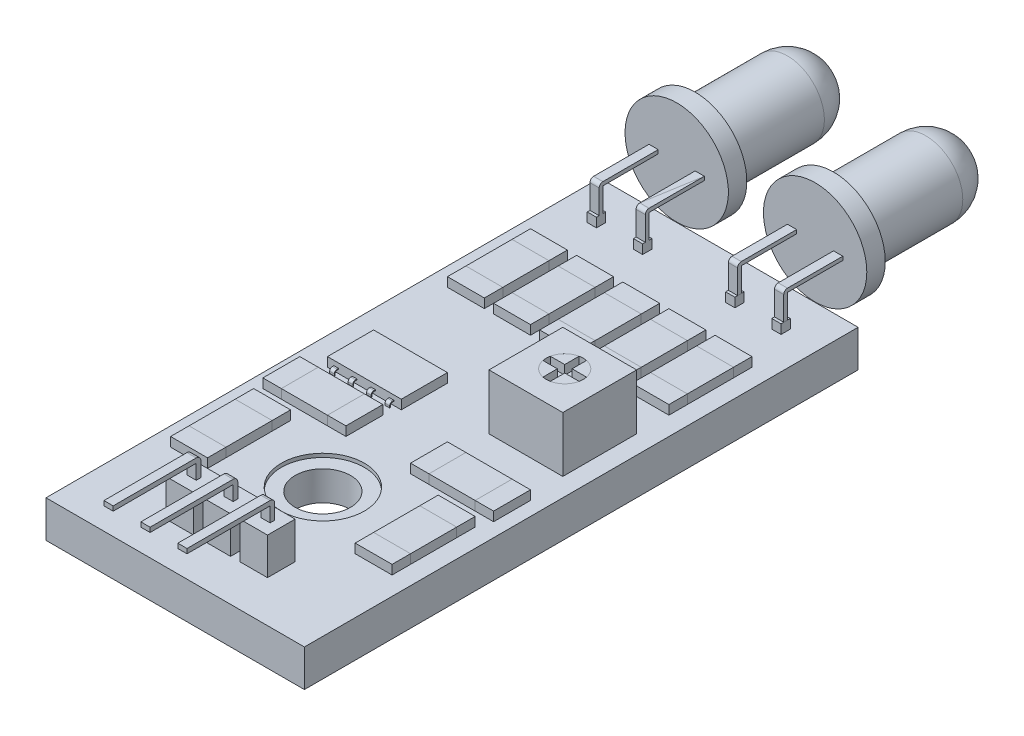
from build123d import *

# Parameters (mm, degrees)
CROQUIS1_W                 = 14
CROQUIS1_H                 = 30
SALIENTE_EXTRUIR1_DEPTH    = 1
CROQUIS2_R                 = 1.5
CORTAR_EXTRUIR1_DEPTH      = 2
CROQUIS3_R                 = 2.25
CORTAR_EXTRUIR2_DEPTH      = 0.2
CROQUIS4_W                 = 1.5
CROQUIS4_H                 = 1.5
SALIENTE_EXTRUIR2_DEPTH    = 2
SALIENTE_EXTRUIR3_START    = -0.75
SALIENTE_EXTRUIR3_DEPTH    = 0.25
MATRIZL1_COUNT             = 3
MATRIZL1_PITCH             = 2
CROQUIS6_W                 = 2
CROQUIS6_H                 = 2.5
SALIENTE_EXTRUIR4_DEPTH    = 0.5
CROQUIS6_3_W               = 2
CROQUIS6_3_H               = 1
SALIENTE_EXTRUIR5_DEPTH    = 0.5
SALIENTE_EXTRUIR5_2_DEPTH  = 0.5
CROQUIS8_W                 = 2.5
CROQUIS8_H                 = 2
SALIENTE_EXTRUIR6_DEPTH    = 0.5
CROQUIS8_3_W               = 1
CROQUIS8_3_H               = 2
SALIENTE_EXTRUIR7_DEPTH    = 0.5
SALIENTE_EXTRUIR7_2_DEPTH  = 0.5
CROQUIS9_W                 = 4
CROQUIS9_H                 = 2.5
SALIENTE_EXTRUIR8_DEPTH    = 0.5
SALIENTE_EXTRUIR9_START    = -0.6
SALIENTE_EXTRUIR9_DEPTH    = 0.25
SALIENTE_EXTRUIR9_2_DEPTH  = 0.25
MATRIZL4_COUNT             = 4
MATRIZL4_PITCH             = 1
CROQUIS11_W                = 4
CROQUIS11_H                = 4
SALIENTE_EXTRUIR10_DEPTH   = 3
CROQUIS12_R                = 1
CORTAR_EXTRUIR3_DEPTH      = 1
CROQUIS13_R                = 1
SALIENTE_EXTRUIR11_DEPTH   = 0.5
SALIENTE_EXTRUIR12_DEPTH   = 0.5
SALIENTE_EXTRUIR12_2_DEPTH = 0.5
SALIENTE_EXTRUIR12_3_DEPTH = 0.5
SALIENTE_EXTRUIR12_4_DEPTH = 0.5
CROQUIS15_W                = 2
CROQUIS15_H                = 2.5
SALIENTE_EXTRUIR13_DEPTH   = 0.5
CROQUIS15_4_W              = 2
CROQUIS15_4_H              = 1
SALIENTE_EXTRUIR14_DEPTH   = 0.5
SALIENTE_EXTRUIR14_2_DEPTH = 0.5
MATRIZL5_COUNT             = 5
MATRIZL5_PITCH             = 2.5
CROQUIS17_W                = 0.5
CROQUIS17_H                = 0.5
SALIENTE_EXTRUIR15_DEPTH   = 0.5
SALIENTE_EXTRUIR15_2_DEPTH = 0.5
SALIENTE_EXTRUIR15_3_DEPTH = 0.5
SALIENTE_EXTRUIR15_4_DEPTH = 0.5
SALIENTE_EXTRUIR16_START   = -0.25
SALIENTE_EXTRUIR16_DEPTH   = 0.25
MATRIZL6_COUNT             = 2
MATRIZL6_PITCH             = 2.5
SIMETR_A16_START           = -0.25
SIMETR_A16_COPY_1_DEPTH    = 0.25


with BuildPart() as part:
    # Croquis1 → Saliente-Extruir1 (new, symmetric)
    with BuildSketch(Plane(origin=(0, 0, 0), x_dir=(1, 0, 0), z_dir=(0, 1, 0))):
        Rectangle(CROQUIS1_W, CROQUIS1_H)
    extrude(amount=SALIENTE_EXTRUIR1_DEPTH, both=True)

    # Croquis2 → Cortar-Extruir1 (cut)
    with BuildSketch(Plane(origin=(0, 1, 0), x_dir=(1, 0, 0), z_dir=(0, 1, 0))):
        with Locations((0, -7)):
            Circle(CROQUIS2_R)
    extrude(amount=-CORTAR_EXTRUIR1_DEPTH, mode=Mode.SUBTRACT)

    # Croquis3 → Cortar-Extruir2 (cut)
    with BuildSketch(Plane(origin=(0, 1, 0), x_dir=(1, 0, 0), z_dir=(0, 1, 0))):
        with Locations((0, -7)):
            Circle(CROQUIS3_R)
    cortar_extruir2 = extrude(amount=-CORTAR_EXTRUIR2_DEPTH, mode=Mode.SUBTRACT)

    # Simetría1: Cortar-Extruir2 across plane
    add(cortar_extruir2.mirror(Plane.ZX), mode=Mode.SUBTRACT)

    # Croquis4 → Saliente-Extruir2 (add)
    with BuildSketch(Plane(origin=(0, 1, 0), x_dir=(1, 0, 0), z_dir=(0, 1, 0))):
        with Locations((-2, -12)):
            Rectangle(CROQUIS4_W, CROQUIS4_H)
        with Locations((0, -12)):
            Rectangle(CROQUIS4_W, CROQUIS4_H)
        with Locations((2, -12)):
            Rectangle(CROQUIS4_W, CROQUIS4_H)
    extrude(amount=SALIENTE_EXTRUIR2_DEPTH)


with BuildPart() as body_2:
    # Croquis5 → Saliente-Extruir3 (new, symmetric)
    with BuildSketch(Plane(origin=(2.75, 0, 0), x_dir=(0, 0, -1), z_dir=(1, 0, 0)).offset(SALIENTE_EXTRUIR3_START)):
        with BuildLine():
            Line((-11.860160095, 3), (-11.860160095, 3.8))
            ThreePointArc((-11.860160095, 3.8), (-11.9333834, 3.976776695), (-12.110160095, 4.05))
            Line((-12.110160095, 4.05), (-16.610160095, 4.05))
            Line((-16.610160095, 4.05), (-16.610160095, 3.8))
            Line((-16.610160095, 3.8), (-12.110160095, 3.8))
            Line((-12.110160095, 3.8), (-12.110160095, 3))
            Line((-12.110160095, 3), (-11.860160095, 3))
        make_face()
    saliente_extruir3 = extrude(amount=SALIENTE_EXTRUIR3_DEPTH, both=True)


with BuildPart() as matrizl1_1:
    # MatrizL1: Saliente-Extruir3 ×3
    with Locations(*[(-i * MATRIZL1_PITCH, 0, 0) for i in range(1, MATRIZL1_COUNT)]):
        add(saliente_extruir3)


with BuildPart() as body_5:
    # Croquis6 → Saliente-Extruir4 (new body)
    with BuildSketch(Plane(origin=(0, 1, 0), x_dir=(1, 0, 0), z_dir=(0, 1, 0))):
        with Locations((5, -6.9999)):
            Rectangle(CROQUIS6_W, CROQUIS6_H)
    extrude(amount=SALIENTE_EXTRUIR4_DEPTH)


with BuildPart() as body_6:
    # Croquis6_3 → Saliente-Extruir5 (new body)
    with BuildSketch(Plane(origin=(0, 1, 0), x_dir=(1, 0, 0), z_dir=(0, 1, 0))):
        with Locations((5, -5.2499)):
            Rectangle(CROQUIS6_3_W, CROQUIS6_3_H)
    extrude(amount=SALIENTE_EXTRUIR5_DEPTH)


with BuildPart() as body_7:
    # Croquis6_3 → Saliente-Extruir5 2 (new body)
    with BuildSketch(Plane(origin=(0, 1, 0), x_dir=(1, 0, 0), z_dir=(0, 1, 0))):
        with Locations((5, -8.7499)):
            Rectangle(CROQUIS6_3_W, CROQUIS6_3_H)
    extrude(amount=SALIENTE_EXTRUIR5_2_DEPTH)


with BuildPart() as body_8:
    # Simetría14: mirrored copy
    add(body_6.part.mirror(Plane(origin=(0, 0, 0), x_dir=(0, 0, 1), z_dir=(1, 0, 0))))


with BuildPart() as body_9:
    # Simetr_a14 2: mirrored copy
    add(body_5.part.mirror(Plane(origin=(0, 0, 0), x_dir=(0, 0, 1), z_dir=(1, 0, 0))))


with BuildPart() as body_10:
    # Simetr_a14 3: mirrored copy
    add(body_7.part.mirror(Plane(origin=(0, 0, 0), x_dir=(0, 0, 1), z_dir=(1, 0, 0))))


with BuildPart() as body_11:
    # Croquis8 → Saliente-Extruir6 (new body)
    with BuildSketch(Plane(origin=(0, 1, 0), x_dir=(1, 0, 0), z_dir=(0, 1, 0))):
        with Locations((4, -3)):
            Rectangle(CROQUIS8_W, CROQUIS8_H)
    extrude(amount=SALIENTE_EXTRUIR6_DEPTH)


with BuildPart() as body_12:
    # Croquis8_3 → Saliente-Extruir7 (new body)
    with BuildSketch(Plane(origin=(0, 1, 0), x_dir=(1, 0, 0), z_dir=(0, 1, 0))):
        with Locations((2.25, -3)):
            Rectangle(CROQUIS8_3_W, CROQUIS8_3_H)
    extrude(amount=SALIENTE_EXTRUIR7_DEPTH)


with BuildPart() as body_13:
    # Croquis8_3 → Saliente-Extruir7 2 (new body)
    with BuildSketch(Plane(origin=(0, 1, 0), x_dir=(1, 0, 0), z_dir=(0, 1, 0))):
        with Locations((5.75, -3)):
            Rectangle(CROQUIS8_3_W, CROQUIS8_3_H)
    extrude(amount=SALIENTE_EXTRUIR7_2_DEPTH)


with BuildPart() as body_14:
    # Simetría15: mirrored copy
    add(body_11.part.mirror(Plane(origin=(0, 0, 0), x_dir=(0, 0, 1), z_dir=(1, 0, 0))))


with BuildPart() as body_15:
    # Simetr_a15 2: mirrored copy
    add(body_13.part.mirror(Plane(origin=(0, 0, 0), x_dir=(0, 0, 1), z_dir=(1, 0, 0))))


with BuildPart() as body_16:
    # Simetr_a15 3: mirrored copy
    add(body_12.part.mirror(Plane(origin=(0, 0, 0), x_dir=(0, 0, 1), z_dir=(1, 0, 0))))


with BuildPart() as body_17:
    # Croquis9 → Saliente-Extruir8 (new body)
    with BuildSketch(Plane(origin=(0, 1, 0), x_dir=(1, 0, 0), z_dir=(0, 1, 0))):
        with Locations((-3.5, 0)):
            Rectangle(CROQUIS9_W, CROQUIS9_H)
    extrude(amount=SALIENTE_EXTRUIR8_DEPTH)


with BuildPart() as body_18:
    # Croquis10 → Saliente-Extruir9 (new body)
    with BuildSketch(Plane.ZY.offset(5.5).offset(SALIENTE_EXTRUIR9_START)):
        with BuildLine():
            Line((1.25, 1.25), (1.33, 1.25))
            ThreePointArc((1.33, 1.25), (1.436066017, 1.206066017), (1.48, 1.1))
            Line((1.48, 1.1), (1.48, 1))
            Line((1.48, 1), (1.43, 1))
            Line((1.43, 1), (1.43, 1.1))
            ThreePointArc((1.43, 1.1), (1.400710678, 1.170710678), (1.33, 1.2))
            Line((1.33, 1.2), (1.25, 1.2))
            Line((1.25, 1.2), (1.25, 1.25))
        make_face()
    saliente_extruir9 = extrude(amount=SALIENTE_EXTRUIR9_DEPTH)


with BuildPart() as body_19:
    # Croquis10 → Saliente-Extruir9 2 (new body)
    with BuildSketch(Plane.ZY.offset(5.5).offset(SALIENTE_EXTRUIR9_START)):
        with BuildLine():
            Line((-1.48, 1), (-1.43, 1))
            Line((-1.43, 1), (-1.43, 1.1))
            ThreePointArc((-1.43, 1.1), (-1.400710678, 1.170710678), (-1.33, 1.2))
            Line((-1.33, 1.2), (-1.25, 1.2))
            Line((-1.25, 1.2), (-1.25, 1.25))
            Line((-1.25, 1.25), (-1.33, 1.25))
            ThreePointArc((-1.33, 1.25), (-1.436066017, 1.206066017), (-1.48, 1.1))
            Line((-1.48, 1.1), (-1.48, 1))
        make_face()
    saliente_extruir9_2 = extrude(amount=SALIENTE_EXTRUIR9_2_DEPTH)


with BuildPart() as matrizl4_1:
    # MatrizL4: Saliente-Extruir9, Saliente-Extruir9 2 ×4
    with Locations(*[(i * MATRIZL4_PITCH, 0, 0) for i in range(1, MATRIZL4_COUNT)]):
        add(saliente_extruir9)
        add(saliente_extruir9_2)


with BuildPart() as body_26:
    # Croquis11 → Saliente-Extruir10 (new body)
    with BuildSketch(Plane(origin=(0, 1, 0), x_dir=(1, 0, 0), z_dir=(0, 1, 0))):
        with Locations((4, 2)):
            Rectangle(CROQUIS11_W, CROQUIS11_H)
    extrude(amount=SALIENTE_EXTRUIR10_DEPTH)

    # Croquis12 → Cortar-Extruir3 (cut)
    with BuildSketch(Plane(origin=(0, 4, 0), x_dir=(1, 0, 0), z_dir=(0, 1, 0))):
        with Locations((4, 2.104018111)):
            Circle(CROQUIS12_R)
    extrude(amount=-CORTAR_EXTRUIR3_DEPTH, mode=Mode.SUBTRACT)


with BuildPart() as body_27:
    # Croquis13 → Saliente-Extruir11 (new body)
    with BuildSketch(Plane(origin=(0, 3, 0), x_dir=(1, 0, 0), z_dir=(0, 1, 0))):
        with Locations((4, 2.104018111)):
            Circle(CROQUIS13_R)
    extrude(amount=SALIENTE_EXTRUIR11_DEPTH)


with BuildPart() as body_28:
    # Croquis14 → Saliente-Extruir12 (new body)
    with BuildSketch(Plane(origin=(0, 3.5, 0), x_dir=(1, 0, 0), z_dir=(0, 1, 0))):
        with BuildLine():
            Line((3.8, 2.304018111), (3.8, 3.083814008))
            ThreePointArc((3.8, 3.083814008), (3.292893219, 2.811124892), (3.020204103, 2.304018111))
            Line((3.020204103, 2.304018111), (3.8, 2.304018111))
        make_face()
    extrude(amount=SALIENTE_EXTRUIR12_DEPTH)


with BuildPart() as body_29:
    # Croquis14 → Saliente-Extruir12 2 (new body)
    with BuildSketch(Plane(origin=(0, 3.5, 0), x_dir=(1, 0, 0), z_dir=(0, 1, 0))):
        with BuildLine():
            ThreePointArc((4.979795897, 2.304018111), (4.707106781, 2.811124892), (4.2, 3.083814008))
            Line((4.2, 3.083814008), (4.2, 2.304018111))
            Line((4.2, 2.304018111), (4.979795897, 2.304018111))
        make_face()
    extrude(amount=SALIENTE_EXTRUIR12_2_DEPTH)


with BuildPart() as body_30:
    # Croquis14 → Saliente-Extruir12 3 (new body)
    with BuildSketch(Plane(origin=(0, 3.5, 0), x_dir=(1, 0, 0), z_dir=(0, 1, 0))):
        with BuildLine():
            Line((3.8, 1.124222214), (3.8, 1.904018111))
            Line((3.8, 1.904018111), (3.020204103, 1.904018111))
            ThreePointArc((3.020204103, 1.904018111), (3.292893219, 1.39691133), (3.8, 1.124222214))
        make_face()
    extrude(amount=SALIENTE_EXTRUIR12_3_DEPTH)


with BuildPart() as body_31:
    # Croquis14 → Saliente-Extruir12 4 (new body)
    with BuildSketch(Plane(origin=(0, 3.5, 0), x_dir=(1, 0, 0), z_dir=(0, 1, 0))):
        with BuildLine():
            Line((4.979795897, 1.904018111), (4.2, 1.904018111))
            Line((4.2, 1.904018111), (4.2, 1.124222214))
            ThreePointArc((4.2, 1.124222214), (4.707106781, 1.39691133), (4.979795897, 1.904018111))
        make_face()
    extrude(amount=SALIENTE_EXTRUIR12_4_DEPTH)


with BuildPart() as body_32:
    # Croquis15 → Saliente-Extruir13 (new body)
    with BuildSketch(Plane(origin=(0, 1, 0), x_dir=(1, 0, 0), z_dir=(0, 1, 0))):
        with Locations((5, 8)):
            Rectangle(CROQUIS15_W, CROQUIS15_H)
    extrude(amount=SALIENTE_EXTRUIR13_DEPTH)


with BuildPart() as body_33:
    # Croquis15_4 → Saliente-Extruir14 (new body)
    with BuildSketch(Plane(origin=(0, 1, 0), x_dir=(1, 0, 0), z_dir=(0, 1, 0))):
        with Locations((5, 6.25)):
            Rectangle(CROQUIS15_4_W, CROQUIS15_4_H)
    extrude(amount=SALIENTE_EXTRUIR14_DEPTH)


with BuildPart() as body_34:
    # Croquis15_4 → Saliente-Extruir14 2 (new body)
    with BuildSketch(Plane(origin=(0, 1, 0), x_dir=(1, 0, 0), z_dir=(0, 1, 0))):
        with Locations((5, 9.75)):
            Rectangle(CROQUIS15_4_W, CROQUIS15_4_H)
    extrude(amount=SALIENTE_EXTRUIR14_2_DEPTH)


with BuildPart() as matrizl5_1:
    # MatrizL5: pattern copy
    add(body_33.part.moved(Location(Vector(-1, 0, 0) * (1 * MATRIZL5_PITCH))))


with BuildPart() as matrizl5_2:
    # MatrizL5: pattern copy
    add(body_33.part.moved(Location(Vector(-1, 0, 0) * (2 * MATRIZL5_PITCH))))


with BuildPart() as matrizl5_3:
    # MatrizL5: pattern copy
    add(body_33.part.moved(Location(Vector(-1, 0, 0) * (3 * MATRIZL5_PITCH))))


with BuildPart() as matrizl5_4:
    # MatrizL5: pattern copy
    add(body_33.part.moved(Location(Vector(-1, 0, 0) * (4 * MATRIZL5_PITCH))))


with BuildPart() as matrizl5_5:
    # MatrizL5: pattern copy
    add(body_32.part.moved(Location(Vector(-1, 0, 0) * (1 * MATRIZL5_PITCH))))


with BuildPart() as matrizl5_6:
    # MatrizL5: pattern copy
    add(body_32.part.moved(Location(Vector(-1, 0, 0) * (2 * MATRIZL5_PITCH))))


with BuildPart() as matrizl5_7:
    # MatrizL5: pattern copy
    add(body_32.part.moved(Location(Vector(-1, 0, 0) * (3 * MATRIZL5_PITCH))))


with BuildPart() as matrizl5_8:
    # MatrizL5: pattern copy
    add(body_32.part.moved(Location(Vector(-1, 0, 0) * (4 * MATRIZL5_PITCH))))


with BuildPart() as matrizl5_9:
    # MatrizL5: pattern copy
    add(body_34.part.moved(Location(Vector(-1, 0, 0) * (1 * MATRIZL5_PITCH))))


with BuildPart() as matrizl5_10:
    # MatrizL5: pattern copy
    add(body_34.part.moved(Location(Vector(-1, 0, 0) * (2 * MATRIZL5_PITCH))))


with BuildPart() as matrizl5_11:
    # MatrizL5: pattern copy
    add(body_34.part.moved(Location(Vector(-1, 0, 0) * (3 * MATRIZL5_PITCH))))


with BuildPart() as matrizl5_12:
    # MatrizL5: pattern copy
    add(body_34.part.moved(Location(Vector(-1, 0, 0) * (4 * MATRIZL5_PITCH))))


with BuildPart() as body_47:
    # Croquis17 → Saliente-Extruir15 (new body)
    with BuildSketch(Plane(origin=(0, 1, 0), x_dir=(1, 0, 0), z_dir=(0, 1, 0))):
        with Locations((-5, 12.824726242)):
            Rectangle(CROQUIS17_W, CROQUIS17_H)
    extrude(amount=SALIENTE_EXTRUIR15_DEPTH)


with BuildPart() as body_48:
    # Croquis17 → Saliente-Extruir15 2 (new body)
    with BuildSketch(Plane(origin=(0, 1, 0), x_dir=(1, 0, 0), z_dir=(0, 1, 0))):
        with Locations((-2.5, 12.824726242)):
            Rectangle(CROQUIS17_W, CROQUIS17_H)
    extrude(amount=SALIENTE_EXTRUIR15_2_DEPTH)


with BuildPart() as body_49:
    # Croquis17 → Saliente-Extruir15 3 (new body)
    with BuildSketch(Plane(origin=(0, 1, 0), x_dir=(1, 0, 0), z_dir=(0, 1, 0))):
        with Locations((2.5, 12.824726242)):
            Rectangle(CROQUIS17_W, CROQUIS17_H)
    extrude(amount=SALIENTE_EXTRUIR15_3_DEPTH)


with BuildPart() as body_50:
    # Croquis17 → Saliente-Extruir15 4 (new body)
    with BuildSketch(Plane(origin=(0, 1, 0), x_dir=(1, 0, 0), z_dir=(0, 1, 0))):
        with Locations((5, 12.824726242)):
            Rectangle(CROQUIS17_W, CROQUIS17_H)
    extrude(amount=SALIENTE_EXTRUIR15_4_DEPTH)


with BuildPart() as body_51:
    # Croquis18 → Saliente-Extruir16 (new, symmetric)
    with BuildSketch(Plane(origin=(5.25, 0, 0), x_dir=(0, 0, -1), z_dir=(1, 0, 0)).offset(SALIENTE_EXTRUIR16_START)):
        with BuildLine():
            Line((12.721362623, 1.5), (12.721362623, 2.8))
            ThreePointArc((12.721362623, 2.8), (12.779941267, 2.941421356), (12.921362623, 3))
            Line((12.921362623, 3), (15.921362623, 3))
            Line((15.921362623, 3), (15.921362623, 2.8))
            Line((15.921362623, 2.8), (12.921362623, 2.8))
            Line((12.921362623, 2.8), (12.921362623, 1.5))
            Line((12.921362623, 1.5), (12.721362623, 1.5))
        make_face()
    saliente_extruir16 = extrude(amount=SALIENTE_EXTRUIR16_DEPTH, both=True)



with BuildPart() as matrizl6_1:
    # MatrizL6: Saliente-Extruir16 ×2
    with Locations(*[(-i * MATRIZL6_PITCH, 0, 0) for i in range(1, MATRIZL6_COUNT)]):
        add(saliente_extruir16)


with BuildPart() as body_47_1:
    add(body_47.part)

    # Simetría16: Saliente-Extruir16 across plane
    add(saliente_extruir16.mirror(Plane(origin=(0, 0, 0), x_dir=(0, 0, 1), z_dir=(1, 0, 0))))

    add(body_48.part)  # Simetría16 copy 1 merges body 48
    # Simetría16 copy 1 sketch → Simetría16 copy 1 (add, symmetric)
    with BuildSketch(Plane(origin=(-2.75, 0, 0), x_dir=(0, 0, -1), z_dir=(-1, 0, 0)).offset(SIMETR_A16_START)):
        with BuildLine():
            Line((12.721362623, -1.5), (12.721362623, -2.8))
            ThreePointArc((12.721362623, -2.8), (12.779941267, -2.941421356), (12.921362623, -3))
            Line((12.921362623, -3), (15.921362623, -3))
            Line((15.921362623, -3), (15.921362623, -2.8))
            Line((15.921362623, -2.8), (12.921362623, -2.8))
            Line((12.921362623, -2.8), (12.921362623, -1.5))
            Line((12.921362623, -1.5), (12.721362623, -1.5))
        make_face()
    extrude(amount=SIMETR_A16_COPY_1_DEPTH, both=True)


with BuildPart() as body_51_1:
    add(body_51.part)

    add(matrizl6_1.part)  # Revolución1 merges MatrizL6_1
    # Croquis19 → Revolución1 (revolve)
    with BuildSketch(Plane(origin=(0, 2.9, 0), x_dir=(1, 0, 0), z_dir=(0, 1, 0))):
        with BuildLine():
            Line((3.75, 15.921362623), (6.55, 15.921362623))
            Line((6.55, 15.921362623), (6.55, 16.921362623))
            Line((6.55, 16.921362623), (5.75, 16.921362623))
            Line((5.75, 16.921362623), (5.75, 21.921362623))
            ThreePointArc((5.75, 21.921362623), (5.164213562, 23.335576185), (3.75, 23.921362623))
            Line((3.75, 23.921362623), (3.75, 15.921362623))
        make_face()
    revolve(axis=Axis((3.75, 2.9, -15.921362623), (0, 0, -1)))


with BuildPart() as body_51_2:
    # Simetría19: mirrored copy
    add(body_51_1.part.mirror(Plane(origin=(0, 0, 0), x_dir=(0, 0, 1), z_dir=(1, 0, 0))))


solid = Compound([part.part, body_2.part, matrizl1_1.part, body_5.part, body_6.part, body_7.part, body_8.part, body_9.part, body_10.part, body_11.part, body_12.part, body_13.part, body_14.part, body_15.part, body_16.part, body_17.part, body_18.part, body_19.part, matrizl4_1.part, body_26.part, body_27.part, body_28.part, body_29.part, body_30.part, body_31.part, body_32.part, body_33.part, body_34.part, matrizl5_1.part, matrizl5_2.part, matrizl5_3.part, matrizl5_4.part, matrizl5_5.part, matrizl5_6.part, matrizl5_7.part, matrizl5_8.part, matrizl5_9.part, matrizl5_10.part, matrizl5_11.part, matrizl5_12.part, body_49.part, body_50.part, body_47_1.part, body_51_1.part, body_51_2.part])
